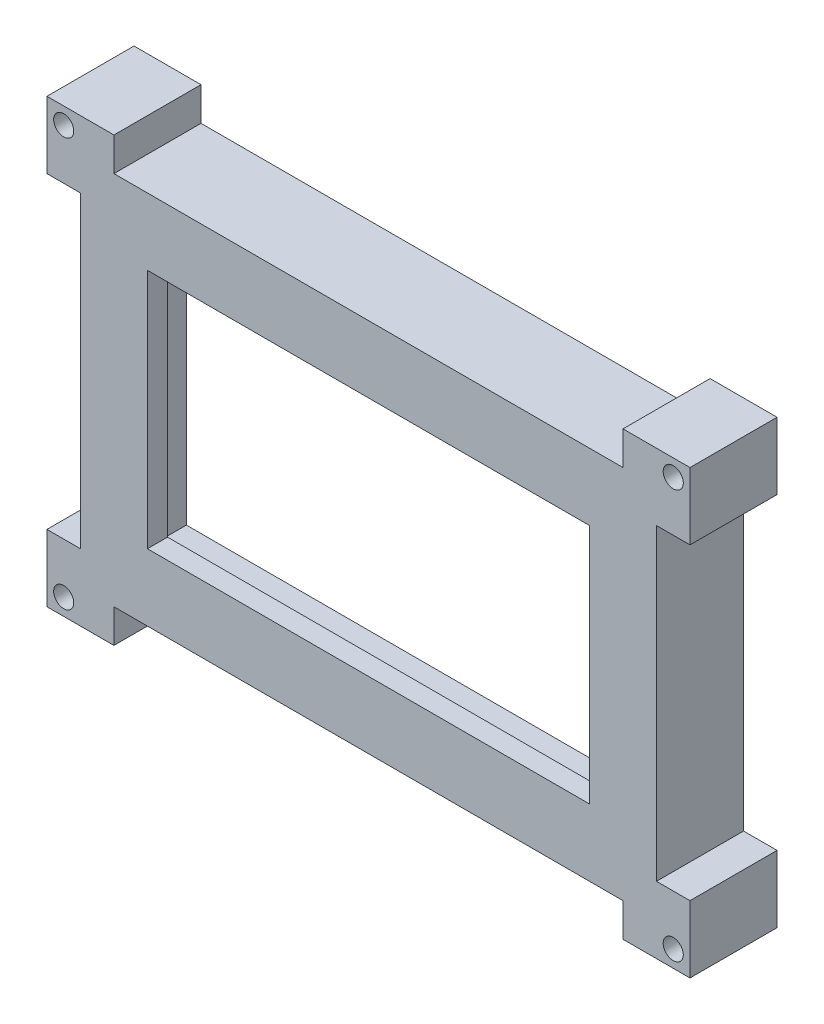
from build123d import *

# Parameters (mm, degrees)
SKETCH1_W               = 86
SKETCH1_H               = 56
SKETCH1_W_2             = 80
SKETCH1_H_2             = 50
BOSS_EXTRUDE1_DEPTH     = 10
SKETCH2_W               = 86
SKETCH2_H               = 56
BOSS_EXTRUDE2_DEPTH     = 3
SKETCH3_W               = 66
SKETCH3_H               = 36
CUT_EXTRUDE1_DEPTH      = 1
CUT_EXTRUDE1_DEPTH_BACK = 14
SKETCH4_W               = 10
SKETCH4_H               = 10
SKETCH4_R               = 1.5
BOSS_EXTRUDE4_DEPTH     = 13
MIRROR6_COPY_1_SKETCH_W = 10
MIRROR6_COPY_1_SKETCH_H = 10
MIRROR6_COPY_1_SKETCH_R = 1.5
MIRROR6_COPY_1_DEPTH    = 13
SKETCH7_W               = 80.18262614
SKETCH7_H               = 50.033838124
CUT_EXTRUDE3_DEPTH      = 10


with BuildPart() as part:
    # Sketch1 → Boss-Extrude1 (new body)
    with BuildSketch(Plane.XY):
        with Locations((2.183359052, -7.007168459)):
            Rectangle(SKETCH1_W, SKETCH1_H)
        with Locations((2.183359052, -7.007168459)):
            Rectangle(SKETCH1_W_2, SKETCH1_H_2, mode=Mode.SUBTRACT)
    extrude(amount=BOSS_EXTRUDE1_DEPTH)

    # Sketch2 → Boss-Extrude2 (add)
    with BuildSketch(Plane.XY.offset(10)):
        with Locations((2.183359052, -7.007168459)):
            Rectangle(SKETCH2_W, SKETCH2_H)
    extrude(amount=BOSS_EXTRUDE2_DEPTH)

    # Sketch3 → Cut-Extrude1 (cut, two sides)
    with BuildSketch(Plane.XY.offset(13)) as cut_extrude1_sk:
        with Locations((2.183359052, -7.007168459)):
            Rectangle(SKETCH3_W, SKETCH3_H)
    extrude(amount=CUT_EXTRUDE1_DEPTH, mode=Mode.SUBTRACT)
    extrude(cut_extrude1_sk.sketch, amount=-CUT_EXTRUDE1_DEPTH_BACK, mode=Mode.SUBTRACT)

    # Sketch4 → Boss-Extrude4 (add)
    with BuildSketch(Plane.XY.offset(13)):
        with Locations((-40.816640948, -35.007168459)):
            Rectangle(SKETCH4_W, SKETCH4_H)
        with Locations((-43.316640948, -37.507168459)):
            Circle(SKETCH4_R, mode=Mode.SUBTRACT)
    boss_extrude4 = extrude(amount=-BOSS_EXTRUDE4_DEPTH)

    # Mirror5: Boss-Extrude4 across plane
    add(boss_extrude4.mirror(Plane.ZY.offset(-2.183359052)))

    # Mirror6: Boss-Extrude4 across plane
    add(boss_extrude4.mirror(Plane(origin=(0, -7.007168459, 0), x_dir=(0, 0, 1), z_dir=(0, -1, 0))))

    # Mirror6 copy 1 sketch → Mirror6 copy 1 (add)
    with BuildSketch(Plane(origin=(4.366718103, -14.014336918, 13), x_dir=(-1, 0, 0), z_dir=(0, 0, 1))):
        with Locations((-40.816640948, -35.007168459)):
            Rectangle(MIRROR6_COPY_1_SKETCH_W, MIRROR6_COPY_1_SKETCH_H)
        with Locations((-43.316640948, -37.507168459)):
            Circle(MIRROR6_COPY_1_SKETCH_R, mode=Mode.SUBTRACT)
    extrude(amount=-MIRROR6_COPY_1_DEPTH)

    # Sketch7 → Cut-Extrude3 (cut)
    with BuildSketch(Plane(origin=(0, 0, 0), x_dir=(-1, 0, 0), z_dir=(0, 0, -1))):
        with Locations((-2.092045982, -7.024087521)):
            Rectangle(SKETCH7_W, SKETCH7_H)
    extrude(amount=-CUT_EXTRUDE3_DEPTH, mode=Mode.SUBTRACT)


solid = part.part
